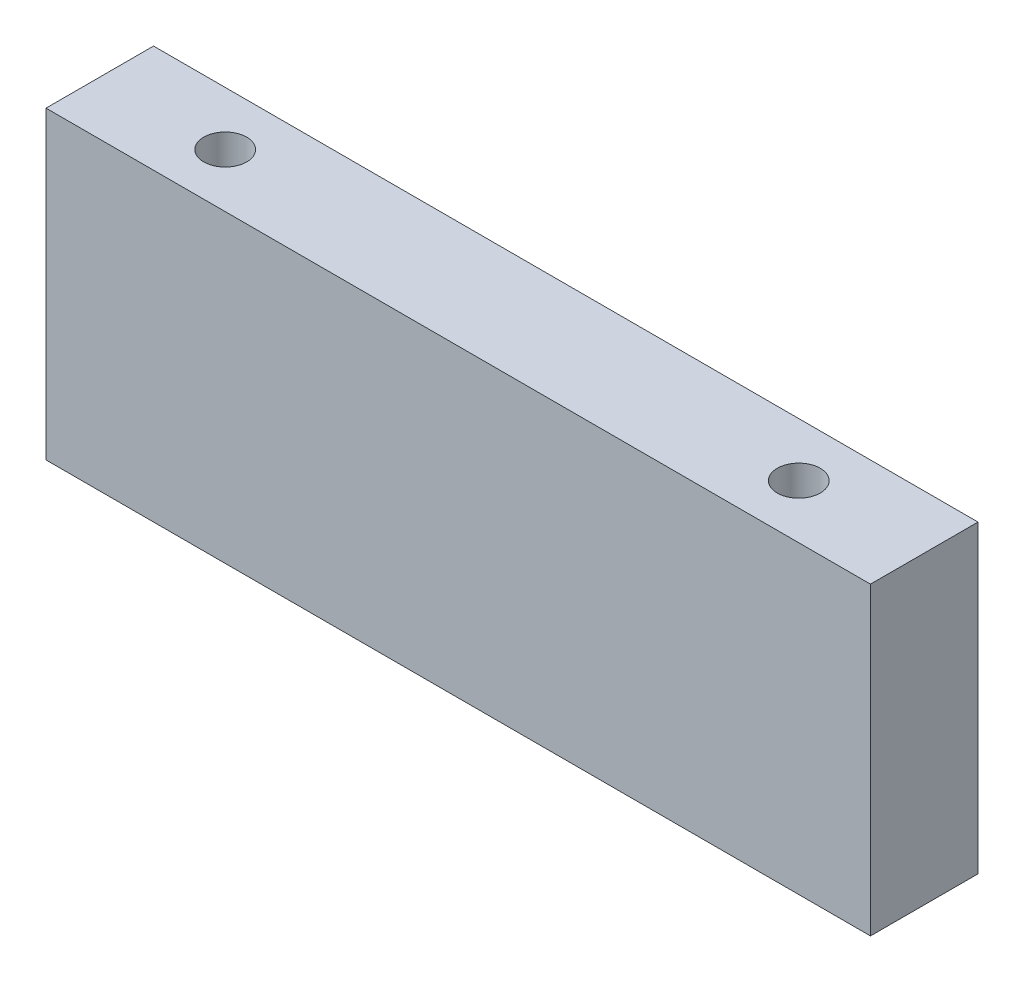
from build123d import *

# Parameters (mm, degrees)
SKETCH1_W           = 115
SKETCH1_H           = 15
BOSS_EXTRUDE1_DEPTH = 42.5
SKETCH2_R           = 3
CUT_EXTRUDE1_DEPTH  = 42.5


with BuildPart() as part:
    # Sketch1 → Boss-Extrude1 (new body)
    with BuildSketch(Plane(origin=(0, 0, 0), x_dir=(1, 0, 0), z_dir=(0, 1, 0))):
        Rectangle(SKETCH1_W, SKETCH1_H)
    extrude(amount=BOSS_EXTRUDE1_DEPTH)

    # Sketch2 → Cut-Extrude1 (cut)
    with BuildSketch(Plane(origin=(0, 42.5, 0), x_dir=(1, 0, 0), z_dir=(0, 1, 0))):
        with Locations((-40, 0)):
            Circle(SKETCH2_R)
        with Locations((40, 0)):
            Circle(SKETCH2_R)
    extrude(amount=-CUT_EXTRUDE1_DEPTH, mode=Mode.SUBTRACT)


solid = part.part
